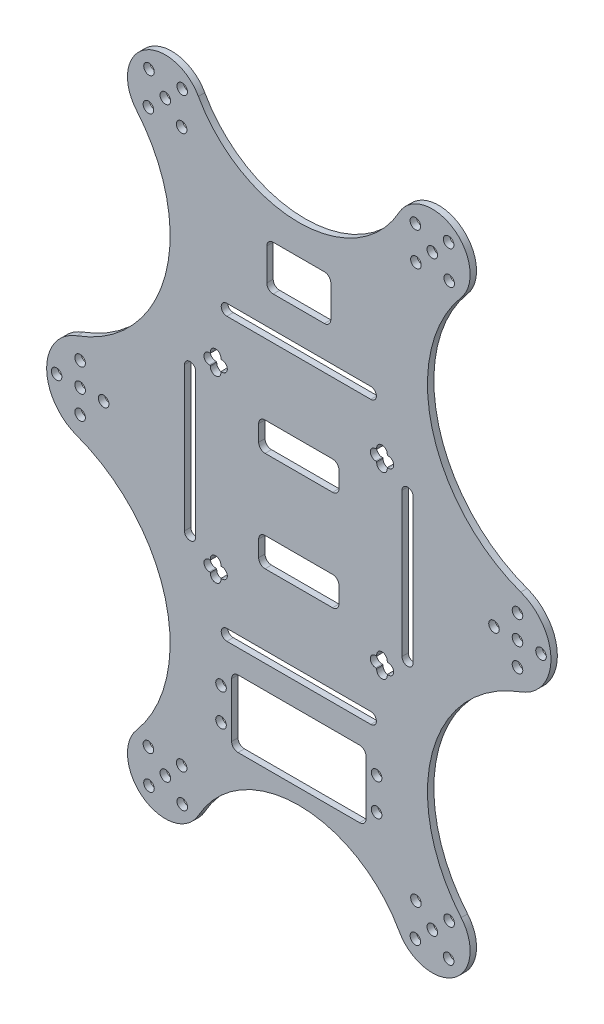
from build123d import *

# Parameters (mm, degrees)
SKETCH_1_R      = 1.65
EXTRUDE_1_DEPTH = 2


with BuildPart() as part:
    # 草图1 → 凸台-拉伸1 (new body)
    with BuildSketch(Plane.XY):
        with BuildLine():
            ThreePointArc((3.478825803, 1.140085793), (31.160613474, 31.487300358), (22.098035112, 71.551055473))
            ThreePointArc((22.098035112, 71.551055473), (22.097226992, 71.552008754), (22.096419384, 71.552962467))
            ThreePointArc((22.096419384, 71.552962467), (24.398037137, 88.92818843), (41.467336112, 84.948872654))
            ThreePointArc((41.467336112, 84.948872654), (72.85197551, 66.494603701), (104.236614907, 84.948872654))
            ThreePointArc((104.236614907, 84.948872654), (121.305913882, 88.92818843), (123.607531636, 71.552962467))
            ThreePointArc((123.607531636, 71.552962467), (123.606724027, 71.552008754), (123.605915908, 71.551055473))
            ThreePointArc((123.605915908, 71.551055473), (114.543337546, 31.487300358), (142.225125217, 1.140085793))
            ThreePointArc((142.225125217, 1.140085793), (151.67398287, -12.372302839), (142.225125217, -25.884691472))
            ThreePointArc((142.225125217, -25.884691472), (114.543337546, -56.231906036), (123.605915908, -96.295661151))
            ThreePointArc((123.605915908, -96.295661151), (123.606724027, -96.296614432), (123.607531636, -96.297568146))
            ThreePointArc((123.607531636, -96.297568146), (121.305913882, -113.672794108), (104.236614907, -109.693478333))
            ThreePointArc((104.236614907, -109.693478333), (72.85197551, -91.23920938), (41.467336112, -109.693478333))
            ThreePointArc((41.467336112, -109.693478333), (24.398037137, -113.672794108), (22.096419384, -96.297568146))
            ThreePointArc((22.096419384, -96.297568146), (22.097226992, -96.296614432), (22.098035112, -96.295661151))
            ThreePointArc((22.098035112, -96.295661151), (31.160613474, -56.231906036), (3.478825803, -25.884691472))
            ThreePointArc((3.478825803, -25.884691472), (-5.97003185, -12.372302839), (3.478825803, 1.140085793))
        make_face()
        with Locations((11.842583941, -12.372302839)):
            Circle(SKETCH_1_R, mode=Mode.SUBTRACT)
        with Locations((119.681841833, 84.617416188)):
            Circle(SKETCH_1_R, mode=Mode.SUBTRACT)
        with Locations((36.414995742, 84.436007679)):
            Circle(SKETCH_1_R, mode=Mode.SUBTRACT)
        with Locations((36.233587233, 74.043121123)):
            Circle(SKETCH_1_R, mode=Mode.SUBTRACT)
        with Locations((4.492583941, -19.722302839)):
            Circle(SKETCH_1_R, mode=Mode.SUBTRACT)
        with Locations((114.57610281, 79.330268656)):
            Circle(SKETCH_1_R, mode=Mode.SUBTRACT)
        with Locations((119.863250342, 74.224529633)):
            Circle(SKETCH_1_R, mode=Mode.SUBTRACT)
        with Locations((109.470363787, 74.043121123)):
            Circle(SKETCH_1_R, mode=Mode.SUBTRACT)
        with Locations((148.561367078, -12.372302839)):
            Circle(SKETCH_1_R, mode=Mode.SUBTRACT)
        with Locations((141.211367078, -19.722302839)):
            Circle(SKETCH_1_R, mode=Mode.SUBTRACT)
        with Locations((141.211367078, -12.372302839)):
            Circle(SKETCH_1_R, mode=Mode.SUBTRACT)
        with Locations((109.288955277, 84.436007679)):
            Circle(SKETCH_1_R, mode=Mode.SUBTRACT)
        with Locations((133.861367078, -12.372302839)):
            Circle(SKETCH_1_R, mode=Mode.SUBTRACT)
        with Locations((141.211367078, -5.022302839)):
            Circle(SKETCH_1_R, mode=Mode.SUBTRACT)
        with Locations((4.492583941, -5.022302839)):
            Circle(SKETCH_1_R, mode=Mode.SUBTRACT)
        with Locations((26.022109187, -109.362021867)):
            Circle(SKETCH_1_R, mode=Mode.SUBTRACT)
        with Locations((31.12784821, -104.074874334)):
            Circle(SKETCH_1_R, mode=Mode.SUBTRACT)
        with Locations((25.840700677, -98.969135312)):
            Circle(SKETCH_1_R, mode=Mode.SUBTRACT)
        with Locations((25.840700677, 74.224529633)):
            Circle(SKETCH_1_R, mode=Mode.SUBTRACT)
        with Locations((31.12784821, 79.330268656)):
            Circle(SKETCH_1_R, mode=Mode.SUBTRACT)
        with Locations((26.022109187, 84.617416188)):
            Circle(SKETCH_1_R, mode=Mode.SUBTRACT)
        with Locations((109.288955277, -109.180613357)):
            Circle(SKETCH_1_R, mode=Mode.SUBTRACT)
        with Locations((109.470363787, -98.787726802)):
            Circle(SKETCH_1_R, mode=Mode.SUBTRACT)
        with Locations((119.863250342, -98.969135312)):
            Circle(SKETCH_1_R, mode=Mode.SUBTRACT)
        with Locations((114.57610281, -104.074874334)):
            Circle(SKETCH_1_R, mode=Mode.SUBTRACT)
        with Locations((36.233587233, -98.787726802)):
            Circle(SKETCH_1_R, mode=Mode.SUBTRACT)
        with Locations((36.414995742, -109.180613357)):
            Circle(SKETCH_1_R, mode=Mode.SUBTRACT)
        with Locations((119.681841833, -109.362021867)):
            Circle(SKETCH_1_R, mode=Mode.SUBTRACT)
        with Locations((48.53697551, -70.977987693)):
            Circle(SKETCH_1_R, mode=Mode.SUBTRACT)
        with Locations((48.53697551, -80.977987693)):
            Circle(SKETCH_1_R, mode=Mode.SUBTRACT)
        with Locations((97.16697551, -80.977987693)):
            Circle(SKETCH_1_R, mode=Mode.SUBTRACT)
        with Locations((97.16697551, -70.977987693)):
            Circle(SKETCH_1_R, mode=Mode.SUBTRACT)
        with Locations((-2.857416059, -12.372302839)):
            Circle(SKETCH_1_R, mode=Mode.SUBTRACT)
        with Locations((4.492583941, -12.372302839)):
            Circle(SKETCH_1_R, mode=Mode.SUBTRACT)
        with BuildLine():
            Line((95.35197551, 33.377697161), (50.35197551, 33.377697161))
            ThreePointArc((50.35197551, 33.377697161), (48.60197551, 31.627697161), (50.35197551, 29.877697161))
            Line((50.35197551, 29.877697161), (95.35197551, 29.877697161))
            ThreePointArc((95.35197551, 29.877697161), (97.10197551, 31.627697161), (95.35197551, 33.377697161))
        make_face(mode=Mode.SUBTRACT)
        with BuildLine():
            Line((40.60197551, 10.127697161), (40.60197551, -34.872302839))
            ThreePointArc((40.60197551, -34.872302839), (38.85197551, -36.622302839), (37.10197551, -34.872302839))
            Line((37.10197551, -34.872302839), (37.10197551, 10.127697161))
            ThreePointArc((37.10197551, 10.127697161), (38.85197551, 11.877697161), (40.60197551, 10.127697161))
        make_face(mode=Mode.SUBTRACT)
        with BuildLine():
            Line((108.60197551, -34.872302839), (108.60197551, 10.127697161))
            ThreePointArc((108.60197551, 10.127697161), (106.85197551, 11.877697161), (105.10197551, 10.127697161))
            Line((105.10197551, 10.127697161), (105.10197551, -34.872302839))
            ThreePointArc((105.10197551, -34.872302839), (106.85197551, -36.622302839), (108.60197551, -34.872302839))
        make_face(mode=Mode.SUBTRACT)
        with BuildLine():
            Line((95.35197551, -58.122302839), (50.35197551, -58.122302839))
            ThreePointArc((50.35197551, -58.122302839), (48.60197551, -56.372302839), (50.35197551, -54.622302839))
            Line((50.35197551, -54.622302839), (95.35197551, -54.622302839))
            ThreePointArc((95.35197551, -54.622302839), (97.10197551, -56.372302839), (95.35197551, -58.122302839))
        make_face(mode=Mode.SUBTRACT)
        with BuildLine():
            Line((80.85197551, 57.151203904), (64.85197551, 57.151203904))
            ThreePointArc((64.85197551, 57.151203904), (63.437761947, 56.565417466), (62.85197551, 55.151203904))
            Line((62.85197551, 55.151203904), (62.85197551, 45.151203904))
            ThreePointArc((62.85197551, 45.151203904), (63.437761947, 43.736990341), (64.85197551, 43.151203904))
            Line((64.85197551, 43.151203904), (80.85197551, 43.151203904))
            ThreePointArc((80.85197551, 43.151203904), (82.266189072, 43.736990341), (82.85197551, 45.151203904))
            Line((82.85197551, 45.151203904), (82.85197551, 55.151203904))
            ThreePointArc((82.85197551, 55.151203904), (82.266189072, 56.565417466), (80.85197551, 57.151203904))
        make_face(mode=Mode.SUBTRACT)
        with BuildLine():
            Line((96.85197551, 17.277697161), (97.20197551, 17.277697161))
            Line((97.20197551, 17.277697161), (97.20197551, 17.627697161))
            ThreePointArc((97.20197551, 17.627697161), (98.85197551, 19.277697161), (100.50197551, 17.627697161))
            Line((100.50197551, 17.627697161), (100.50197551, 17.277697161))
            Line((100.50197551, 17.277697161), (100.85197551, 17.277697161))
            ThreePointArc((100.85197551, 17.277697161), (102.50197551, 15.627697161), (100.85197551, 13.977697161))
            Line((100.85197551, 13.977697161), (100.50197551, 13.977697161))
            Line((100.50197551, 13.977697161), (100.50197551, 13.627697161))
            ThreePointArc((100.50197551, 13.627697161), (98.85197551, 11.977697161), (97.20197551, 13.627697161))
            Line((97.20197551, 13.627697161), (97.20197551, 13.977697161))
            Line((97.20197551, 13.977697161), (96.85197551, 13.977697161))
            ThreePointArc((96.85197551, 13.977697161), (95.20197551, 15.627697161), (96.85197551, 17.277697161))
        make_face(mode=Mode.SUBTRACT)
        with BuildLine():
            Line((48.85197551, 13.977697161), (48.50197551, 13.977697161))
            Line((48.50197551, 13.977697161), (48.50197551, 13.627697161))
            ThreePointArc((48.50197551, 13.627697161), (46.85197551, 11.977697161), (45.20197551, 13.627697161))
            Line((45.20197551, 13.627697161), (45.20197551, 13.977697161))
            Line((45.20197551, 13.977697161), (44.85197551, 13.977697161))
            ThreePointArc((44.85197551, 13.977697161), (43.20197551, 15.627697161), (44.85197551, 17.277697161))
            Line((44.85197551, 17.277697161), (45.20197551, 17.277697161))
            Line((45.20197551, 17.277697161), (45.20197551, 17.627697161))
            ThreePointArc((45.20197551, 17.627697161), (46.85197551, 19.277697161), (48.50197551, 17.627697161))
            Line((48.50197551, 17.627697161), (48.50197551, 17.277697161))
            Line((48.50197551, 17.277697161), (48.85197551, 17.277697161))
            ThreePointArc((48.85197551, 17.277697161), (50.50197551, 15.627697161), (48.85197551, 13.977697161))
        make_face(mode=Mode.SUBTRACT)
        with BuildLine():
            Line((97.20197551, -38.372302839), (97.20197551, -38.722302839))
            Line((97.20197551, -38.722302839), (96.85197551, -38.722302839))
            ThreePointArc((96.85197551, -38.722302839), (95.20197551, -40.372302839), (96.85197551, -42.022302839))
            Line((96.85197551, -42.022302839), (97.20197551, -42.022302839))
            Line((97.20197551, -42.022302839), (97.20197551, -42.372302839))
            ThreePointArc((97.20197551, -42.372302839), (98.85197551, -44.022302839), (100.50197551, -42.372302839))
            Line((100.50197551, -42.372302839), (100.50197551, -42.022302839))
            Line((100.50197551, -42.022302839), (100.85197551, -42.022302839))
            ThreePointArc((100.85197551, -42.022302839), (102.50197551, -40.372302839), (100.85197551, -38.722302839))
            Line((100.85197551, -38.722302839), (100.50197551, -38.722302839))
            Line((100.50197551, -38.722302839), (100.50197551, -38.372302839))
            ThreePointArc((100.50197551, -38.372302839), (98.85197551, -36.722302839), (97.20197551, -38.372302839))
        make_face(mode=Mode.SUBTRACT)
        with BuildLine():
            Line((48.85197551, -42.022302839), (48.50197551, -42.022302839))
            Line((48.50197551, -42.022302839), (48.50197551, -42.372302839))
            ThreePointArc((48.50197551, -42.372302839), (46.85197551, -44.022302839), (45.20197551, -42.372302839))
            Line((45.20197551, -42.372302839), (45.20197551, -42.022302839))
            Line((45.20197551, -42.022302839), (44.85197551, -42.022302839))
            ThreePointArc((44.85197551, -42.022302839), (43.20197551, -40.372302839), (44.85197551, -38.722302839))
            Line((44.85197551, -38.722302839), (45.20197551, -38.722302839))
            Line((45.20197551, -38.722302839), (45.20197551, -38.372302839))
            ThreePointArc((45.20197551, -38.372302839), (46.85197551, -36.722302839), (48.50197551, -38.372302839))
            Line((48.50197551, -38.372302839), (48.50197551, -38.722302839))
            Line((48.50197551, -38.722302839), (48.85197551, -38.722302839))
            ThreePointArc((48.85197551, -38.722302839), (50.50197551, -40.372302839), (48.85197551, -42.022302839))
        make_face(mode=Mode.SUBTRACT)
        with BuildLine():
            Line((62.302643165, -23.484959883), (83.401307855, -23.484959883))
            ThreePointArc((83.401307855, -23.484959883), (84.815521417, -24.07074632), (85.401307855, -25.484959883))
            Line((85.401307855, -25.484959883), (85.401307855, -30.509582097))
            ThreePointArc((85.401307855, -30.509582097), (84.815521417, -31.923795659), (83.401307855, -32.509582097))
            Line((83.401307855, -32.509582097), (62.302643165, -32.509582097))
            ThreePointArc((62.302643165, -32.509582097), (60.888429603, -31.923795659), (60.302643165, -30.509582097))
            Line((60.302643165, -30.509582097), (60.302643165, -25.484959883))
            ThreePointArc((60.302643165, -25.484959883), (60.888429603, -24.07074632), (62.302643165, -23.484959883))
        make_face(mode=Mode.SUBTRACT)
        with BuildLine():
            Line((62.302643165, 7.764976418), (83.401307855, 7.764976418))
            ThreePointArc((83.401307855, 7.764976418), (84.815521417, 7.17918998), (85.401307855, 5.764976418))
            Line((85.401307855, 5.764976418), (85.401307855, 0.740354204))
            ThreePointArc((85.401307855, 0.740354204), (84.815521417, -0.673859358), (83.401307855, -1.259645796))
            Line((83.401307855, -1.259645796), (62.302643165, -1.259645796))
            ThreePointArc((62.302643165, -1.259645796), (60.888429603, -0.673859358), (60.302643165, 0.740354204))
            Line((60.302643165, 0.740354204), (60.302643165, 5.764976418))
            ThreePointArc((60.302643165, 5.764976418), (60.888429603, 7.17918998), (62.302643165, 7.764976418))
        make_face(mode=Mode.SUBTRACT)
        with BuildLine():
            Line((53.85197551, -65.477987693), (91.85197551, -65.477987693))
            ThreePointArc((91.85197551, -65.477987693), (93.266189072, -66.063774131), (93.85197551, -67.477987693))
            Line((93.85197551, -67.477987693), (93.85197551, -84.477987693))
            ThreePointArc((93.85197551, -84.477987693), (93.266189072, -85.892201255), (91.85197551, -86.477987693))
            Line((91.85197551, -86.477987693), (53.85197551, -86.477987693))
            ThreePointArc((53.85197551, -86.477987693), (52.437761947, -85.892201255), (51.85197551, -84.477987693))
            Line((51.85197551, -84.477987693), (51.85197551, -67.477987693))
            ThreePointArc((51.85197551, -67.477987693), (52.437761947, -66.063774131), (53.85197551, -65.477987693))
        make_face(mode=Mode.SUBTRACT)
    extrude(amount=EXTRUDE_1_DEPTH)


solid = part.part
